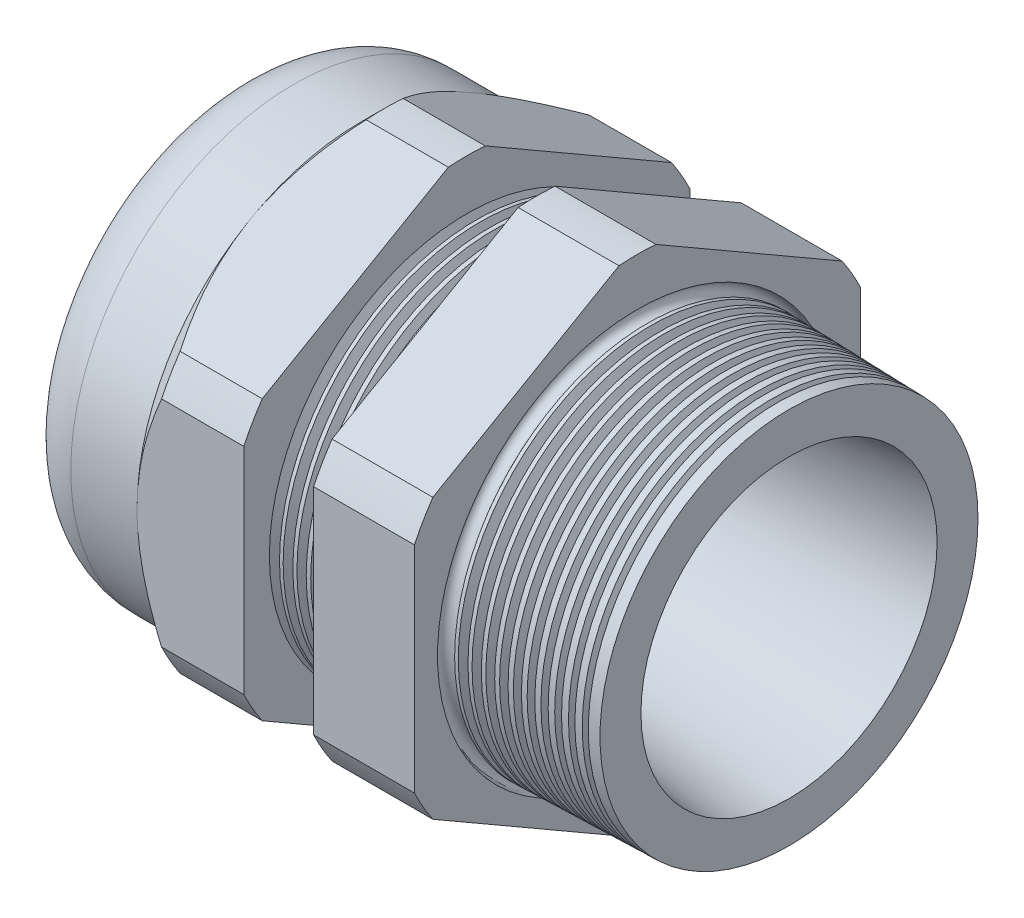
from build123d import *

# Parameters (mm, degrees)
LPATTERN6_COUNT    = 5
LPATTERN6_PITCH    = 1.5748
LPATTERN7_COUNT    = 11
LPATTERN7_PITCH    = 1.5748
SKETCH12_OUTSIDE_W = 140.978
SKETCH12_OUTSIDE_H = 140.978
CUT_EXTRUDE2_DEPTH = 52.04003
FILLET4_R          = 7.112
SKETCH19_OUTSIDE_W = 83.724
SKETCH19_OUTSIDE_H = 89.564
SKETCH19_OUTSIDE_R = 26.543
CUT_EXTRUDE3_DEPTH = 3.99796
CUT_EXTRUDE3_DRAFT = -45
SKETCH28_R         = 0.9525


with BuildPart() as part:
    # Sketch10 → Revolve2 (revolve)
    with BuildSketch(Plane.XY, mode=Mode.PRIVATE) as revolve2_sk:
        Polygon((-40.88003, 12.954), (-28.18003, 12.954), (10.16, 17.62125), (10.16, 22.491030981), (-7.874, 22.963267891), (-7.874, 53.086), (-19.873976, 53.086), (-19.873976, 23.277498321), (-28.18003, 23.495), (-28.18003, 53.086), (-40.88003, 53.086), (-40.88003, 26.543), (-55.88, 26.543), (-55.88, 17.62125), (-40.88003, 17.62125), align=None)
    revolve(revolve2_sk.sketch.rotate(Axis((0, 0, 0), (-1, 0, 0)), 90), axis=Axis((0, 0, 0), (-1, 0, 0)))  # turned: the seam where the file's is

    # Sketch26 → Cut-Revolve1 (revolve, cut)
    with BuildSketch(Plane.XY, mode=Mode.PRIVATE) as cut_revolve1_sk:
        Polygon((-28.18003, 23.495), (-27.007256271, 23.464289839), (-27.620238915, 22.463993077), align=None)
    cut_revolve1 = revolve(cut_revolve1_sk.sketch.rotate(Axis((0, 0, 0), (-1, 0, 0)), 90), axis=Axis((0, 0, 0), (-1, 0, 0)), mode=Mode.SUBTRACT)  # turned: the seam where the file's is

    # LPattern6: Cut-Revolve1 ×5
    with Locations(*[(i * LPATTERN6_PITCH, 0, 0) for i in range(1, LPATTERN6_COUNT)]):
        add(cut_revolve1, mode=Mode.SUBTRACT)

    # Sketch27 → Cut-Revolve2 (revolve, cut)
    with BuildSketch(Plane.XY, mode=Mode.PRIVATE) as cut_revolve2_sk:
        Polygon((-7.874, 22.963267891), (-6.701226271, 22.93255773), (-7.314208915, 21.932260968), align=None)
    cut_revolve2 = revolve(cut_revolve2_sk.sketch.rotate(Axis((0, 0, 0), (-1, 0, 0)), 90), axis=Axis((0, 0, 0), (-1, 0, 0)), mode=Mode.SUBTRACT)  # turned: the seam where the file's is

    # LPattern7: Cut-Revolve2 ×11
    with Locations(*[(i * LPATTERN7_PITCH, 0, 0) for i in range(1, LPATTERN7_COUNT)]):
        add(cut_revolve2, mode=Mode.SUBTRACT)

    # Sketch12 outside → Cut-Extrude2 (cut, through all)
    with BuildSketch(Plane.ZY.offset(40.88003)):
        Rectangle(SKETCH12_OUTSIDE_W, SKETCH12_OUTSIDE_H)
        with BuildLine():
            Line((-2.19715092, 29.380690715), (-24.34584908, 16.59313387))
            ThreePointArc((-24.34584908, 16.59313387), (-25.515472645, 14.731365), (-26.543, 12.787556845))
            Line((-26.543, 12.787556845), (-26.543, -12.787556845))
            ThreePointArc((-26.543, -12.787556845), (-25.515472645, -14.731365), (-24.34584908, -16.59313387))
            Line((-24.34584908, -16.59313387), (-2.19715092, -29.380690715))
            ThreePointArc((-2.19715092, -29.380690715), (0, -29.46273), (2.19715092, -29.380690715))
            Line((2.19715092, -29.380690715), (24.34584908, -16.59313387))
            ThreePointArc((24.34584908, -16.59313387), (25.515472645, -14.731365), (26.543, -12.787556845))
            Line((26.543, -12.787556845), (26.543, 12.787556845))
            ThreePointArc((26.543, 12.787556845), (25.515472645, 14.731365), (24.34584908, 16.59313387))
            Line((24.34584908, 16.59313387), (2.19715092, 29.380690715))
            ThreePointArc((2.19715092, 29.380690715), (0, 29.46273), (-2.19715092, 29.380690715))
        make_face(mode=Mode.SUBTRACT)
    extrude(amount=-CUT_EXTRUDE2_DEPTH, mode=Mode.SUBTRACT)

    # Fillet4
    fillet4_edges = [part.edges().sort_by_distance(p)[0] for p in [
        (-55.88, 0, 26.543),
    ]]
    fillet(fillet4_edges, radius=FILLET4_R)


with BuildPart() as body_2:
    # Sketch30 → Revolve8 (revolve)
    with BuildSketch(Plane.XY, mode=Mode.PRIVATE) as revolve8_sk:
        with BuildLine():
            Line((-54.8894, 17.62125), (-40.88003, 17.62125))
            Line((-40.88003, 17.62125), (-40.88003, 12.954))
            Line((-40.88003, 12.954), (-55.118, 12.954))
            Line((-55.118, 12.954), (-55.118, 17.39265))
            ThreePointArc((-55.118, 17.39265), (-55.05104461, 17.55429461), (-54.8894, 17.62125))
        make_face()
    revolve(revolve8_sk.sketch.rotate(Axis((0, 0, 0), (-1, 0, 0)), 270), axis=Axis((0, 0, 0), (-1, 0, 0)))  # turned: the seam where the file's is


with BuildPart() as cut_extrude3_tool:
    # Sketch19 outside → Cut-Extrude3 (with draft: the straight prism first)
    with BuildSketch(Plane.ZY.offset(40.88003)):
        Rectangle(SKETCH19_OUTSIDE_W, SKETCH19_OUTSIDE_H)
        Circle(SKETCH19_OUTSIDE_R, mode=Mode.SUBTRACT)
    extrude(amount=-CUT_EXTRUDE3_DEPTH)
    # Cut-Extrude3: the draft: its side faces are tilted about the plane it starts from
    cut_extrude3_sides = [cut_extrude3_tool.faces().sort_by_distance(p)[0] for p in [
        (-38.88105, -44.782, 0),
        (-38.88105, 0, 41.862),
        (-38.88105, 44.782, 0),
        (-38.88105, 0, -41.862),
        (-38.88105, 0, -26.543),
    ]]
    draft(cut_extrude3_sides, Plane.ZY.offset(40.88003), CUT_EXTRUDE3_DRAFT)


with BuildPart() as part_1:
    add(part.part)

    # Cut-Extrude3: cut by cut_extrude3_tool
    add(cut_extrude3_tool.part, mode=Mode.SUBTRACT)

    # Sketch28 → Cut-Revolve3 (revolve, cut)
    with BuildSketch(Plane.XY, mode=Mode.PRIVATE) as cut_revolve3_sk:
        with Locations((-7.8486, -22.836267891)):
            Circle(SKETCH28_R)
    revolve(cut_revolve3_sk.sketch.rotate(Axis((10.16, 0, 0), (-1, 0, 0)), 90), axis=Axis((10.16, 0, 0), (-1, 0, 0)), mode=Mode.SUBTRACT)  # turned: the seam where the file's is


solid = Compound([body_2.part, part_1.part])
